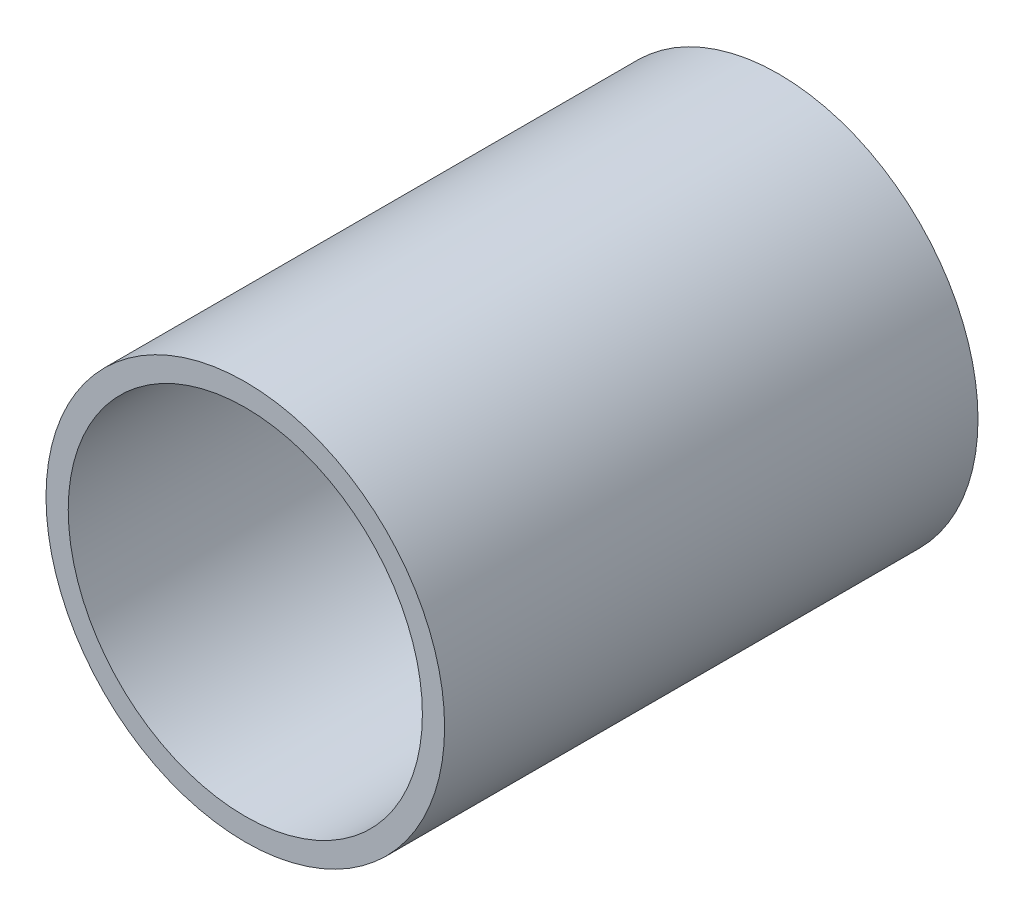
from build123d import *

# Parameters (mm, degrees)
SKETCH1_R           = 56.945
SKETCH1_R_2         = 50.595
BOSS_EXTRUDE1_DEPTH = 152.4


with BuildPart() as part:
    # Sketch1 → Boss-Extrude1 (new body)
    with BuildSketch(Plane.XY):
        Circle(SKETCH1_R)
        Circle(SKETCH1_R_2, mode=Mode.SUBTRACT)
    extrude(amount=BOSS_EXTRUDE1_DEPTH)


solid = part.part
